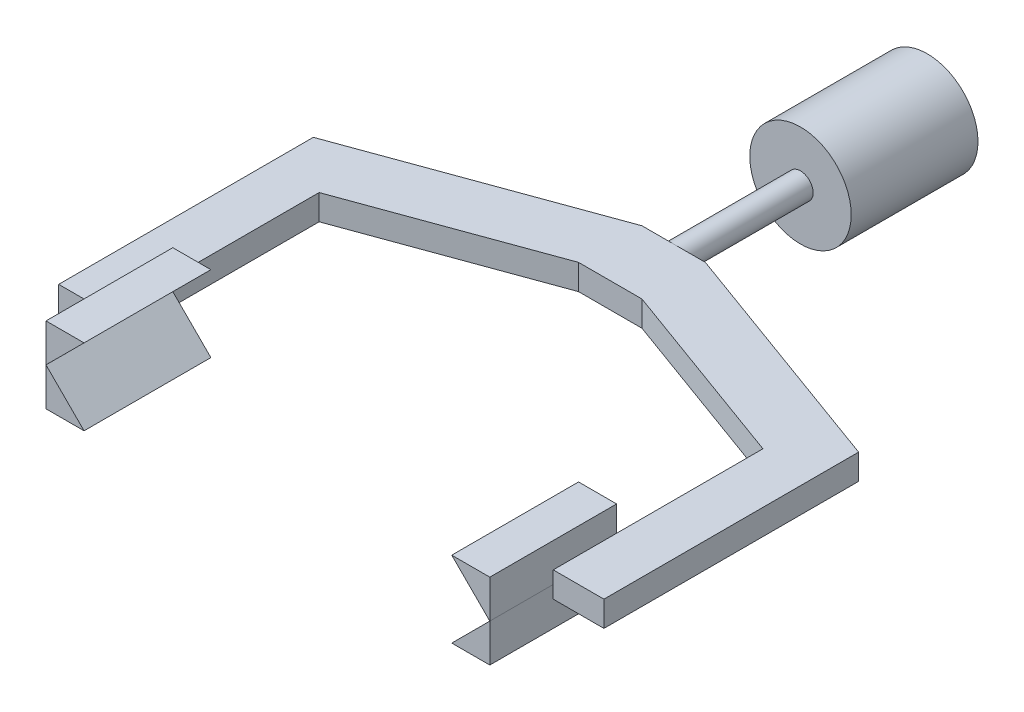
from build123d import *

# Parameters (mm, degrees)
SKETCH1_R             = 4
BOSS_EXTRUDE1_DEPTH   = 10
SKETCH2_R             = 1
BOSS_EXTRUDE2_DEPTH   = 10
SKETCH3_W             = 5
SKETCH3_H             = 5
BOSS_EXTRUDE3_DEPTH   = 1
BOSS_EXTRUDE4_DEPTH   = 1
BOSS_EXTRUDE7_DEPTH   = 5
BOSS_EXTRUDE7_2_DEPTH = 5
BOSS_EXTRUDE7_3_DEPTH = 5
BOSS_EXTRUDE7_4_DEPTH = 5


with BuildPart() as part:
    # Sketch1 → Boss-Extrude1 (new body)
    with BuildSketch(Plane.XY):
        Circle(SKETCH1_R)
    extrude(amount=BOSS_EXTRUDE1_DEPTH)

    # Sketch2 → Boss-Extrude2 (add)
    with BuildSketch(Plane.XY.offset(10)):
        Circle(SKETCH2_R)
    extrude(amount=BOSS_EXTRUDE2_DEPTH)

    # Sketch3 → Boss-Extrude3 (add, symmetric)
    with BuildSketch(Plane(origin=(0, 0, 0), x_dir=(1, 0, 0), z_dir=(0, 1, 0))):
        with Locations((0, -22.5)):
            Rectangle(SKETCH3_W, SKETCH3_H)
    extrude(amount=BOSS_EXTRUDE3_DEPTH, both=True)

    # Sketch5 → Boss-Extrude4 (add, symmetric)
    with BuildSketch(Plane(origin=(0, 0, 0), x_dir=(1, 0, 0), z_dir=(0, 1, 0))):
        Polygon((2.5, -20), (21.5, -26.915434451), (21.5, -47), (17.5, -47), (17.5, -30.459553514), (2.5, -25), align=None)
    boss_extrude4 = extrude(amount=BOSS_EXTRUDE4_DEPTH, both=True)

    # Mirror1: Boss-Extrude4 across plane
    add(boss_extrude4.mirror(Plane(origin=(0, 0, 0), x_dir=(0, 0, 1), z_dir=(1, 0, 0))))


with BuildPart() as body_2:
    # Sketch6 → Boss-Extrude7 (new body, symmetric)
    with BuildSketch(Plane.XY.offset(47)):
        Polygon((17.5, 0), (14.497168083, -3.002831917), (17.5, -3.002831917), align=None)
    extrude(amount=BOSS_EXTRUDE7_DEPTH, both=True)


with BuildPart() as body_3:
    # Sketch6 → Boss-Extrude7 2 (new body, symmetric)
    with BuildSketch(Plane.XY.offset(47)):
        Polygon((17.5, 0), (17.5, 3.002831917), (14.497168083, 3.002831917), align=None)
    extrude(amount=BOSS_EXTRUDE7_2_DEPTH, both=True)


with BuildPart() as body_4:
    # Sketch6 → Boss-Extrude7 3 (new body, symmetric)
    with BuildSketch(Plane.XY.offset(47)):
        Polygon((-17.5, 3.002831917), (-17.5, 0.002831917), (-14.497168083, 3.002831917), align=None)
    extrude(amount=BOSS_EXTRUDE7_3_DEPTH, both=True)


with BuildPart() as body_5:
    # Sketch6 → Boss-Extrude7 4 (new body, symmetric)
    with BuildSketch(Plane.XY.offset(47)):
        Polygon((-14.497168083, -3.002831917), (-17.5, 0), (-17.5, -3.002831917), align=None)
    extrude(amount=BOSS_EXTRUDE7_4_DEPTH, both=True)


solid = Compound([part.part, body_2.part, body_3.part, body_4.part, body_5.part])
